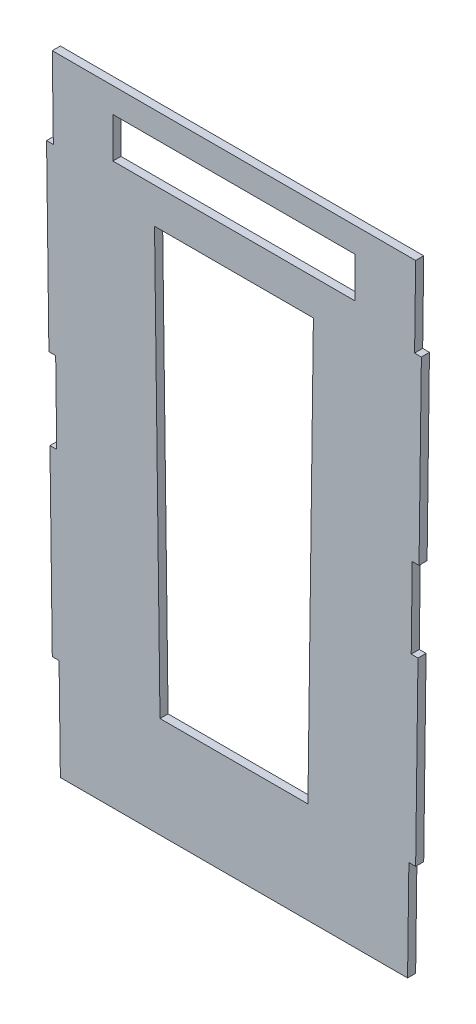
from build123d import *

# Parameters (mm, degrees)
SKETCH1_W           = 60
SKETCH1_H           = 10
BOSS_EXTRUDE1_DEPTH = 2


with BuildPart() as part:
    # Sketch1 → Boss-Extrude1 (new body)
    with BuildSketch(Plane.XY):
        Polygon((90, 0), (0, 0), (0.258301591, -19.998335275), (-1.418256709, -19.998335275), (-0.837659875, -64.994589645), (0.839480171, -64.994589645), (1.097803264, -84.994589645), (-0.579595357, -84.994589645), (0.001001477, -129.990844015), (1.678981844, -129.990844015), (2.001001477, -154.922384552), (88.001001477, -154.922384552), (88.322698776, -129.990844015), (90.001001477, -129.990844015), (90.581598311, -84.994589645), (88.903295611, -84.994589645), (89.161360128, -64.994589645), (90.839662829, -64.994589645), (91.420259663, -19.998335275), (89.741956963, -19.998335275), align=None)
        Polygon((25.324989117, -25), (64.675338274, -25), (63.321501046, -129.922384552), (26.680182862, -129.922384552), align=None, mode=Mode.SUBTRACT)
        with Locations((45.001001477, -11.176996481)):
            Rectangle(SKETCH1_W, SKETCH1_H, mode=Mode.SUBTRACT)
    extrude(amount=BOSS_EXTRUDE1_DEPTH)


solid = part.part
